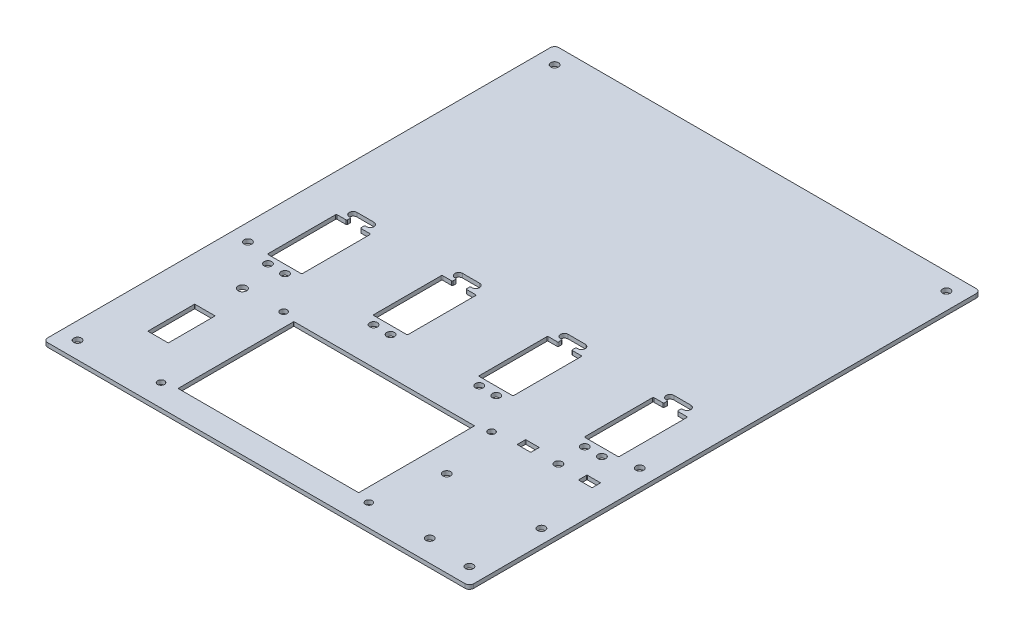
from build123d import *

# Parameters (mm, degrees)
SKETCH1_W              = 250
SKETCH1_H              = 300
BOSS_EXTRUDE1_DEPTH    = 2.38125
SKETCH2_W              = 20.2
SKETCH2_H              = 40.5
CUT_EXTRUDE1_DEPTH     = 3.38125
SKETCH3_R              = 2.25
CUT_EXTRUDE2_DEPTH     = 3.38125
FILLET1_R              = 0.5
LPATTERN1_COUNT        = 4
LPATTERN1_PITCH        = 62
FILLET1_OF_LPATTERN1_R = 0.5
SKETCH4_W              = 106
SKETCH4_H              = 68
CUT_EXTRUDE3_DEPTH     = 3.38125
SKETCH5_W              = 8
SKETCH5_H              = 5
SKETCH5_W_2            = 12
SKETCH5_H_2            = 27.5
CUT_EXTRUDE4_DEPTH     = 3.38125
FILLET2_R              = 0.25
SKETCH6_R              = 2
CUT_EXTRUDE5_DEPTH     = 3.38125
SKETCH7_R              = 2.25
CUT_EXTRUDE6_DEPTH     = 3.38125
FILLET3_R              = 2.5
CUT_EXTRUDE7_REACH     = 4.381
SKETCH8_R              = 2.25
CUT_EXTRUDE8_REACH     = 4.381
SKETCH9_R              = 2.5


with BuildPart() as part:
    # Sketch1 → Boss-Extrude1 (new body)
    with BuildSketch(Plane(origin=(0, 0, 0), x_dir=(1, 0, 0), z_dir=(0, 1, 0))):
        with Locations((125, 150)):
            Rectangle(SKETCH1_W, SKETCH1_H)
    extrude(amount=BOSS_EXTRUDE1_DEPTH)

    # Sketch2 → Cut-Extrude1 (cut, through all)
    with BuildSketch(Plane(origin=(0, 2.38125, 0), x_dir=(1, 0, 0), z_dir=(0, 1, 0))):
        with Locations((32, 129.75)):
            Rectangle(SKETCH2_W, SKETCH2_H)
    cut_extrude1 = extrude(amount=-CUT_EXTRUDE1_DEPTH, mode=Mode.SUBTRACT)

    # Sketch3 → Cut-Extrude2 (cut, through all)
    with BuildSketch(Plane(origin=(0, 2.38125, 0), x_dir=(1, 0, 0), z_dir=(0, 1, 0))):
        with Locations((37, 104.75)):
            Circle(SKETCH3_R)
        with Locations((27, 104.75)):
            Circle(SKETCH3_R)
        with BuildLine():
            Line((28, 157), (27, 157))
            ThreePointArc((27, 157), (24.80939278, 154.236443763), (28, 152.734435563))
            Line((28, 152.734435563), (28, 150))
            Line((28, 150), (36, 150))
            Line((36, 150), (36, 152.734435563))
            ThreePointArc((36, 152.734435563), (39.19060722, 154.236443763), (37, 157))
            Line((37, 157), (36, 157))
            Line((36, 157), (28, 157))
        make_face()
    cut_extrude2 = extrude(amount=-CUT_EXTRUDE2_DEPTH, mode=Mode.SUBTRACT)

    # Fillet1
    fillet1_edges = [part.edges().sort_by_distance(p)[0] for p in [
        (21.9, 1.190625, -109.5),
        (21.9, 1.190625, -150),
        (42.1, 1.190625, -150),
        (42.1, 1.190625, -109.5),
        (36, 1.190625, -152.734435563),
        (36, 1.190625, -150),
        (28, 1.190625, -150),
        (28, 1.190625, -152.734435563),
    ]]
    fillet(fillet1_edges, radius=FILLET1_R)

    # LPattern1: Cut-Extrude1, Cut-Extrude2 ×4
    with Locations(*[(i * LPATTERN1_PITCH, 0, 0) for i in range(1, LPATTERN1_COUNT)]):
        add(cut_extrude1, mode=Mode.SUBTRACT)
        add(cut_extrude2, mode=Mode.SUBTRACT)

    # Fillet1 of LPattern1
    fillet1_of_lpattern1_edges = [part.edges().sort_by_distance(p)[0] for p in [
        (83.9, 1.190625, -109.5),
        (83.9, 1.190625, -150),
        (104.1, 1.190625, -150),
        (104.1, 1.190625, -109.5),
        (98, 1.190625, -152.734435563),
        (98, 1.190625, -150),
        (90, 1.190625, -150),
        (90, 1.190625, -152.734435563),
        (145.9, 1.190625, -109.5),
        (145.9, 1.190625, -150),
        (166.1, 1.190625, -150),
        (166.1, 1.190625, -109.5),
        (160, 1.190625, -152.734435563),
        (160, 1.190625, -150),
        (152, 1.190625, -150),
        (152, 1.190625, -152.734435563),
        (207.9, 1.190625, -109.5),
        (207.9, 1.190625, -150),
        (228.1, 1.190625, -150),
        (228.1, 1.190625, -109.5),
        (222, 1.190625, -152.734435563),
        (222, 1.190625, -150),
        (214, 1.190625, -150),
        (214, 1.190625, -152.734435563),
    ]]
    fillet(fillet1_of_lpattern1_edges, radius=FILLET1_OF_LPATTERN1_R)

    # Sketch4 → Cut-Extrude3 (cut, through all)
    with BuildSketch(Plane(origin=(0, 2.38125, 0), x_dir=(1, 0, 0), z_dir=(0, 1, 0))):
        with Locations((117, 49)):
            Rectangle(SKETCH4_W, SKETCH4_H)
    extrude(amount=-CUT_EXTRUDE3_DEPTH, mode=Mode.SUBTRACT)

    # Sketch5 → Cut-Extrude4 (cut, through all)
    with BuildSketch(Plane(origin=(0, 2.38125, 0), x_dir=(1, 0, 0), z_dir=(0, 1, 0))):
        with Locations((196, 88.5)):
            Rectangle(SKETCH5_W, SKETCH5_H)
        with Locations((232, 88.5)):
            Rectangle(SKETCH5_W, SKETCH5_H)
        with Locations((32, 49)):
            Rectangle(SKETCH5_W_2, SKETCH5_H_2)
    extrude(amount=-CUT_EXTRUDE4_DEPTH, mode=Mode.SUBTRACT)

    # Fillet2
    fillet2_edges = [part.edges().sort_by_distance(p)[0] for p in [
        (64, 1.190625, -15),
        (64, 1.190625, -83),
        (170, 1.190625, -83),
        (170, 1.190625, -15),
        (26, 1.190625, -35.25),
        (26, 1.190625, -62.75),
        (38, 1.190625, -62.75),
        (38, 1.190625, -35.25),
        (228, 1.190625, -86),
        (228, 1.190625, -91),
        (236, 1.190625, -91),
        (236, 1.190625, -86),
        (192, 1.190625, -86),
        (192, 1.190625, -91),
        (200, 1.190625, -91),
        (200, 1.190625, -86),
    ]]
    fillet(fillet2_edges, radius=FILLET2_R)

    # Sketch6 → Cut-Extrude5 (cut, through all)
    with BuildSketch(Plane(origin=(0, 2.38125, 0), x_dir=(1, 0, 0), z_dir=(0, 1, 0))):
        with Locations((56, 85)):
            Circle(SKETCH6_R)
        with Locations((178, 85)):
            Circle(SKETCH6_R)
        with Locations((178, 13)):
            Circle(SKETCH6_R)
        with Locations((56, 13)):
            Circle(SKETCH6_R)
    extrude(amount=-CUT_EXTRUDE5_DEPTH, mode=Mode.SUBTRACT)

    # Sketch7 → Cut-Extrude6 (cut, through all)
    with BuildSketch(Plane(origin=(0, 2.38125, 0), x_dir=(1, 0, 0), z_dir=(0, 1, 0))):
        with Locations((10, 290)):
            Circle(SKETCH7_R)
        with Locations((240, 290)):
            Circle(SKETCH7_R)
        with Locations((240, 110)):
            Circle(SKETCH7_R)
        with Locations((240, 10)):
            Circle(SKETCH7_R)
        with Locations((10, 10)):
            Circle(SKETCH7_R)
        with Locations((10, 110)):
            Circle(SKETCH7_R)
    extrude(amount=-CUT_EXTRUDE6_DEPTH, mode=Mode.SUBTRACT)

    # Fillet3
    fillet3_edges = [part.edges().sort_by_distance(p)[0] for p in [
        (0, 1.190625, -300),
        (250, 1.190625, -300),
        (250, 1.190625, 0),
        (0, 1.190625, 0),
    ]]
    fillet(fillet3_edges, radius=FILLET3_R)

    # Sketch8 → Cut-Extrude7 (cut, up to next)
    with BuildSketch(Plane(origin=(0, 2.38125, 0), x_dir=(1, 0, 0), z_dir=(0, 1, 0)), mode=Mode.PRIVATE) as cut_extrude7_sk1:
        with Locations((214, 88.25)):
            Circle(SKETCH8_R)
    cut_extrude7_tool1 = extrude(cut_extrude7_sk1.sketch, amount=-CUT_EXTRUDE7_REACH, mode=Mode.PRIVATE) & part.part
    add(cut_extrude7_tool1.solids().sort_by_distance((214, 2.38125, -88.25))[0], mode=Mode.SUBTRACT)
    # Sketch8 → Cut-Extrude7 (cut, up to next)
    with BuildSketch(Plane(origin=(0, 2.38125, 0), x_dir=(1, 0, 0), z_dir=(0, 1, 0)), mode=Mode.PRIVATE) as cut_extrude7_sk2:
        with Locations((241.75, 50.5)):
            Circle(SKETCH8_R)
    cut_extrude7_tool2 = extrude(cut_extrude7_sk2.sketch, amount=-CUT_EXTRUDE7_REACH, mode=Mode.PRIVATE) & part.part
    add(cut_extrude7_tool2.solids().sort_by_distance((241.75, 2.38125, -50.5))[0], mode=Mode.SUBTRACT)
    # Sketch8 → Cut-Extrude7 (cut, up to next)
    with BuildSketch(Plane(origin=(0, 2.38125, 0), x_dir=(1, 0, 0), z_dir=(0, 1, 0)), mode=Mode.PRIVATE) as cut_extrude7_sk3:
        with Locations((214, 12.75)):
            Circle(SKETCH8_R)
    cut_extrude7_tool3 = extrude(cut_extrude7_sk3.sketch, amount=-CUT_EXTRUDE7_REACH, mode=Mode.PRIVATE) & part.part
    add(cut_extrude7_tool3.solids().sort_by_distance((214, 2.38125, -12.75))[0], mode=Mode.SUBTRACT)
    # Sketch8 → Cut-Extrude7 (cut, up to next)
    with BuildSketch(Plane(origin=(0, 2.38125, 0), x_dir=(1, 0, 0), z_dir=(0, 1, 0)), mode=Mode.PRIVATE) as cut_extrude7_sk4:
        with Locations((186.25, 50.5)):
            Circle(SKETCH8_R)
    cut_extrude7_tool4 = extrude(cut_extrude7_sk4.sketch, amount=-CUT_EXTRUDE7_REACH, mode=Mode.PRIVATE) & part.part
    add(cut_extrude7_tool4.solids().sort_by_distance((186.25, 2.38125, -50.5))[0], mode=Mode.SUBTRACT)

    # Sketch9 → Cut-Extrude8 (cut, up to next)
    with BuildSketch(Plane(origin=(0, 2.38125, 0), x_dir=(1, 0, 0), z_dir=(0, 1, 0)), mode=Mode.PRIVATE) as cut_extrude8_sk1:
        with Locations((32, 84.75)):
            Circle(SKETCH9_R)
    cut_extrude8_tool1 = extrude(cut_extrude8_sk1.sketch, amount=-CUT_EXTRUDE8_REACH, mode=Mode.PRIVATE) & part.part
    add(cut_extrude8_tool1.solids().sort_by_distance((32, 2.38125, -84.75))[0], mode=Mode.SUBTRACT)


solid = part.part
